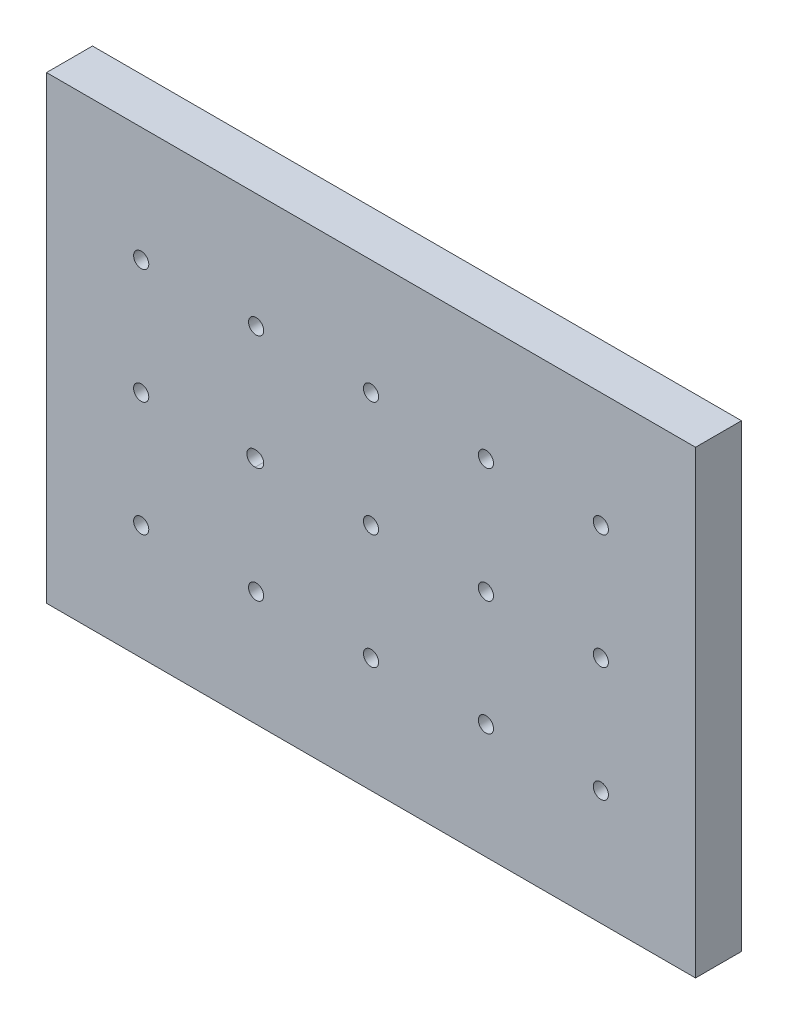
from build123d import *

# Parameters (mm, degrees)
SKETCH1_W             = 141.2
SKETCH1_H             = 100
BOSS_EXTRUDE1_DEPTH   = 10
M4X0_7_TAPPED_HOLE1_D = 3.3


with BuildPart() as part:
    # Sketch1 → Boss-Extrude1 (new body)
    with BuildSketch(Plane.XY):
        with Locations((-70.6, 50)):
            Rectangle(SKETCH1_W, SKETCH1_H)
    extrude(amount=BOSS_EXTRUDE1_DEPTH)

    # M4x0.7 Tapped Hole1 (through all)
    with Locations(Plane.XY.offset(10)):
        with Locations((-120.6, 75), (-70.6, 50), (-95.6, 50), (-20.6, 50), (-45.6, 50), (-95.972807971, 50), (-120.6, 50), (-20.6, 25), (-45.6, 25), (-70.6, 25), (-95.6, 25), (-120.6, 25), (-20.6, 75), (-45.6, 75), (-70.6, 75), (-95.6, 75)):
            Hole(M4X0_7_TAPPED_HOLE1_D / 2)


solid = part.part
